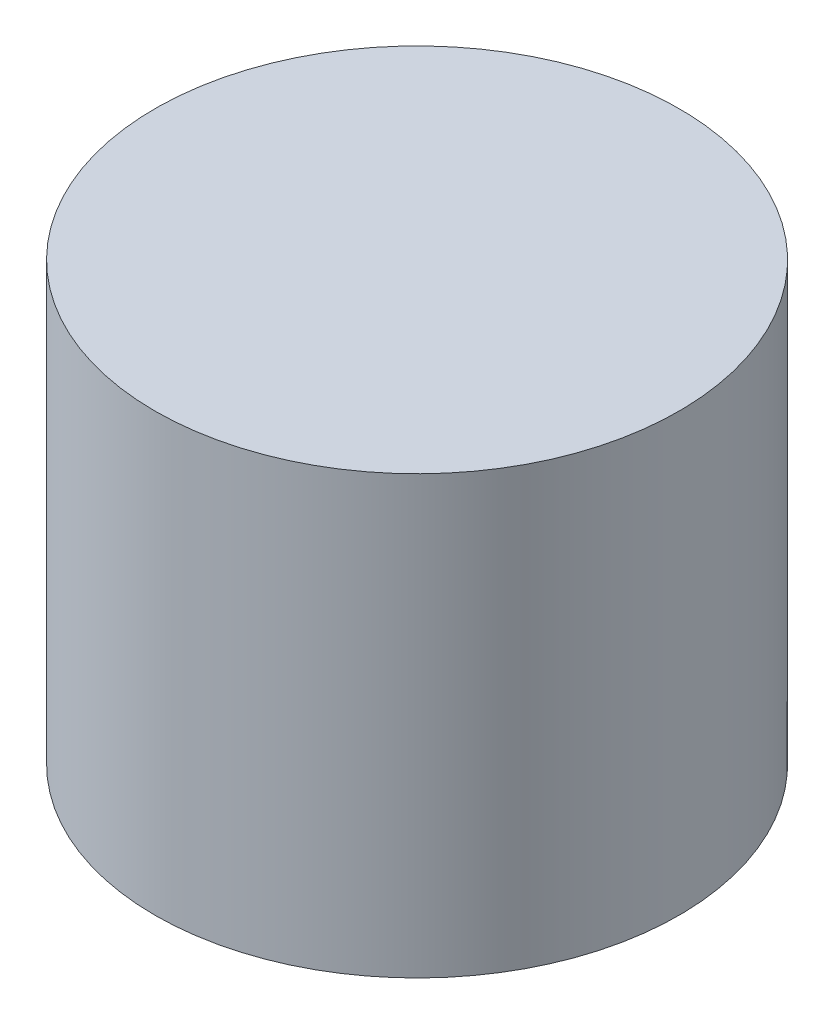
from build123d import *

# Parameters (mm, degrees)
SKETCH1_R           = 6
BOSS_EXTRUDE1_DEPTH = 10


with BuildPart() as part:
    # Sketch1 → Boss-Extrude1 (new body)
    with BuildSketch(Plane(origin=(0, 0, 0), x_dir=(1, 0, 0), z_dir=(0, 1, 0))):
        Circle(SKETCH1_R)
    extrude(amount=BOSS_EXTRUDE1_DEPTH)


solid = part.part
